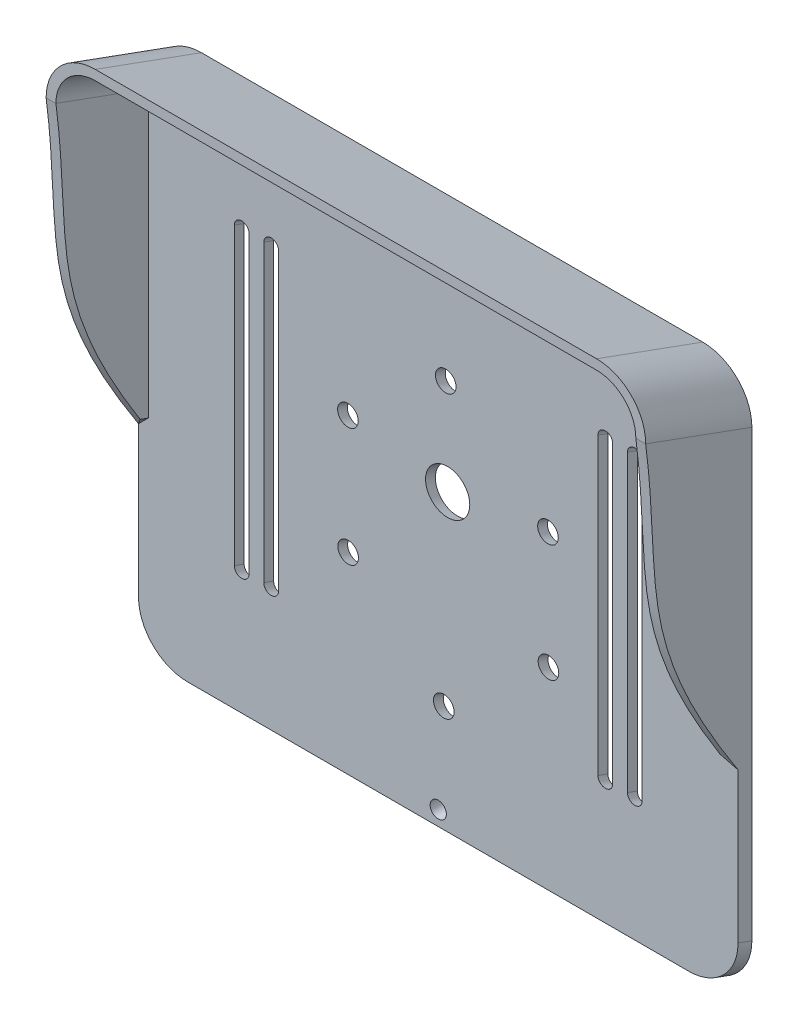
from build123d import *

# Parameters (mm, degrees)
SALIENTE_EXTRUIR1_DEPTH    = 3
SALIENTE_EXTRUIR2_DEPTH    = 3
VACIADO1_T                 = -2
CROQUIS2_R                 = 2.1
CROQUIS2_R_2               = 4.5
AGUJEROS_FRONTALES_DEPTH   = 2.128355545
SALIENTE_EXTRUIR3_DEPTH    = 20
CORTAR_EXTRUIR2_DEPTH      = 140.049655499
CORTAR_EXTRUIR2_DEPTH_BACK = 140.049655499
CORTAR_EXTRUIR3_REACH      = 91.766
CROQUIS6_R                 = 1.65


with BuildPart() as part:
    # Croquis1 → Saliente-Extruir1 (new, along a direction that is not the sketch's normal)
    with BuildSketch(Plane.XY):
        with BuildLine():
            Line((51, 55.25), (-51, 55.25))
            ThreePointArc((-51, 55.25), (-58.071067812, 52.321067812), (-61, 45.25))
            Line((-61, 45.25), (-61, 38.85))
            Line((-61, 38.85), (-61, -45.25))
            ThreePointArc((-61, -45.25), (-58.071067812, -52.321067812), (-51, -55.25))
            Line((-51, -55.25), (51, -55.25))
            ThreePointArc((51, -55.25), (58.071067812, -52.321067812), (61, -45.25))
            Line((61, -45.25), (61, 38.85))
            Line((61, 38.85), (61, 45.25))
            ThreePointArc((61, 45.25), (58.071067812, 52.321067812), (51, 55.25))
        make_face()
        with BuildLine():
            ThreePointArc((-54.6, -38.85), (-51.671067812, -45.921067812), (-44.6, -48.85))
            Line((-44.6, -48.85), (44.6, -48.85))
            ThreePointArc((44.6, -48.85), (51.671067812, -45.921067812), (54.6, -38.85))
            Line((54.6, -38.85), (54.6, 33.85))
            Line((54.6, 33.85), (54.6, 38.85))
            ThreePointArc((54.6, 38.85), (51.671067812, 45.921067812), (44.6, 48.85))
            Line((44.6, 48.85), (-44.6, 48.85))
            ThreePointArc((-44.6, 48.85), (-51.671067812, 45.921067812), (-54.6, 38.85))
            Line((-54.6, 38.85), (-54.6, 33.85))
            Line((-54.6, 33.85), (-54.6, -38.85))
        make_face(mode=Mode.SUBTRACT)
        with BuildLine():
            Line((-54.6, 33.85), (-54.6, -38.85))
            ThreePointArc((-54.6, -38.85), (-51.671067812, -45.921067812), (-44.6, -48.85))
            Line((-44.6, -48.85), (44.6, -48.85))
            ThreePointArc((44.6, -48.85), (51.671067812, -45.921067812), (54.6, -38.85))
            Line((54.6, -38.85), (54.6, 33.85))
            Line((54.6, 33.85), (54.6, 38.85))
            ThreePointArc((54.6, 38.85), (51.671067812, 45.921067812), (44.6, 48.85))
            Line((44.6, 48.85), (-44.6, 48.85))
            ThreePointArc((-44.6, 48.85), (-51.671067812, 45.921067812), (-54.6, 38.85))
            Line((-54.6, 38.85), (-54.6, 33.85))
        make_face()
    extrude(amount=SALIENTE_EXTRUIR1_DEPTH, dir=(0, 0.34202014332566943, 0.9396926207859081))

    # Croquis1_3 → Saliente-Extruir2 (add, along a direction that is not the sketch's normal)
    with BuildSketch(Plane.XY):
        with BuildLine():
            Line((-54.6, 33.85), (-54.6, -38.85))
            ThreePointArc((-54.6, -38.85), (-51.671067812, -45.921067812), (-44.6, -48.85))
            Line((-44.6, -48.85), (44.6, -48.85))
            ThreePointArc((44.6, -48.85), (51.671067812, -45.921067812), (54.6, -38.85))
            Line((54.6, -38.85), (54.6, 33.85))
            Line((54.6, 33.85), (54.6, 38.85))
            ThreePointArc((54.6, 38.85), (51.671067812, 45.921067812), (44.6, 48.85))
            Line((44.6, 48.85), (-44.6, 48.85))
            ThreePointArc((-44.6, 48.85), (-51.671067812, 45.921067812), (-54.6, 38.85))
            Line((-54.6, 38.85), (-54.6, 33.85))
        make_face()
    extrude(amount=-SALIENTE_EXTRUIR2_DEPTH, dir=(0, 0.34202014332566943, 0.9396926207859081))

    # Vaciado1
    vaciado1_openings = [part.faces().sort_by_distance(p)[0] for p in [
        (0, -1.02606043, -2.819077862),
    ]]
    offset(amount=VACIADO1_T, openings=vaciado1_openings, kind=Kind.INTERSECTION)

    # Croquis2 → agujeros_frontales (cut, along a direction that is not the sketch's normal)
    with BuildSketch(Plane.XY.offset(2.819077862)):
        with Locations((1.522820459, 25.074336596)):
            Circle(CROQUIS2_R)
        with Locations((22.322818653, 8.874338039)):
            Circle(CROQUIS2_R)
        with Locations((22.422820346, -14.925662509)):
            Circle(CROQUIS2_R)
        with Locations((1.122821138, -32.425665611)):
            Circle(CROQUIS2_R)
        with Locations((-18.337182685, -15.02566234)):
            Circle(CROQUIS2_R)
        with Locations((-18.377177401, 9.074337699)):
            Circle(CROQUIS2_R)
        with Locations((1.910269276, 5.696006038)):
            Circle(CROQUIS2_R_2)
        with BuildLine():
            Line((-41.5, -28.97393957), (-41.5, 31.02606043))
            ThreePointArc((-41.5, 31.02606043), (-40, 32.52606043), (-38.5, 31.02606043))
            Line((-38.5, 31.02606043), (-38.5, -28.97393957))
            ThreePointArc((-38.5, -28.97393957), (-40, -30.47393957), (-41.5, -28.97393957))
        make_face()
        with BuildLine():
            Line((-32.5, -28.97393957), (-32.5, 31.02606043))
            ThreePointArc((-32.5, 31.02606043), (-34, 32.52606043), (-35.5, 31.02606043))
            Line((-35.5, 31.02606043), (-35.5, -28.97393957))
            ThreePointArc((-35.5, -28.97393957), (-34, -30.47393957), (-32.5, -28.97393957))
        make_face()
        with BuildLine():
            Line((41.5, -28.97393957), (41.5, 31.02606043))
            ThreePointArc((41.5, 31.02606043), (40, 32.52606043), (38.5, 31.02606043))
            Line((38.5, 31.02606043), (38.5, -28.97393957))
            ThreePointArc((38.5, -28.97393957), (40, -30.47393957), (41.5, -28.97393957))
        make_face()
        with BuildLine():
            Line((35.5, -28.97393957), (35.5, 31.02606043))
            ThreePointArc((35.5, 31.02606043), (34, 32.52606043), (32.5, 31.02606043))
            Line((32.5, 31.02606043), (32.5, -28.97393957))
            ThreePointArc((32.5, -28.97393957), (34, -30.47393957), (35.5, -28.97393957))
        make_face()
    extrude(amount=-AGUJEROS_FRONTALES_DEPTH, dir=(0, 0.34202014332566943, 0.9396926207859081), mode=Mode.SUBTRACT)

    # Croquis4 → Saliente-Extruir3 (add, along a direction that is not the sketch's normal)
    with BuildSketch(Plane.XY.offset(2.819077862)):
        with BuildLine():
            ThreePointArc((61, 46.27606043), (58.071067812, 53.347128242), (51, 56.27606043))
            Line((51, 56.27606043), (0, 56.27606043))
            Line((0, 56.27606043), (0, 54.27606043))
            Line((0, 54.27606043), (51, 54.27606043))
            ThreePointArc((51, 54.27606043), (56.656854249, 51.932914679), (59, 46.27606043))
            Line((59, 46.27606043), (59, -11.72393957))
            Line((59, -11.72393957), (61, -13.72393957))
            Line((61, -13.72393957), (61, 46.27606043))
        make_face()
        with BuildLine():
            Line((0, 54.27606043), (0, 56.27606043))
            Line((0, 56.27606043), (-51, 56.27606043))
            ThreePointArc((-51, 56.27606043), (-58.071067812, 53.347128242), (-61, 46.27606043))
            Line((-61, 46.27606043), (-61, -11.72393957))
            Line((-61, -11.72393957), (-61, -13.72393957))
            Line((-61, -13.72393957), (-59, -11.72393957))
            Line((-59, -11.72393957), (-59, 46.27606043))
            ThreePointArc((-59, 46.27606043), (-56.656854249, 51.932914679), (-51, 54.27606043))
            Line((-51, 54.27606043), (0, 54.27606043))
        make_face()
    extrude(amount=SALIENTE_EXTRUIR3_DEPTH, dir=(0, 0.3420201433256695, 0.9396926207859082))

    # Croquis5 → Cortar-Extruir2 (cut, two sides)
    with BuildSketch(Plane(origin=(61, 0, 0), x_dir=(0, 0, -1), z_dir=(1, 0, 0))) as cortar_extruir2_sk:
        with BuildLine():
            Line((-21.612930278, 53.116463296), (-21.612930278, -13.72393957))
            Line((-21.612930278, -13.72393957), (-2.819077862, -13.72393957))
            add(Edge.make_bspline(
                [(-21.612930278, 53.116463296), (-18.192805265, 26.402020841), (-24.202213901, 19.250300864), (-2.819077862, -13.72393957)],
                knots=[0.10784476, 0.10784476, 0.10784476, 0.10784476, 1, 1, 1, 1], degree=3))
        make_face()
    extrude(amount=CORTAR_EXTRUIR2_DEPTH, mode=Mode.SUBTRACT)
    extrude(cortar_extruir2_sk.sketch, amount=-CORTAR_EXTRUIR2_DEPTH_BACK, mode=Mode.SUBTRACT)

    # Croquis6 → Cortar-Extruir3 (cut, up to next)
    with BuildSketch(Plane.XY.offset(2.819077862), mode=Mode.PRIVATE) as cortar_extruir3_sk1:
        with Locations((0, -51.22393957)):
            Circle(CROQUIS6_R)
    cortar_extruir3_tool1 = extrude(cortar_extruir3_sk1.sketch, amount=-CORTAR_EXTRUIR3_REACH, mode=Mode.PRIVATE) & part.part
    add(cortar_extruir3_tool1.solids().sort_by_distance((0, -51.22394, 2.819078))[0], mode=Mode.SUBTRACT)


solid = part.part
